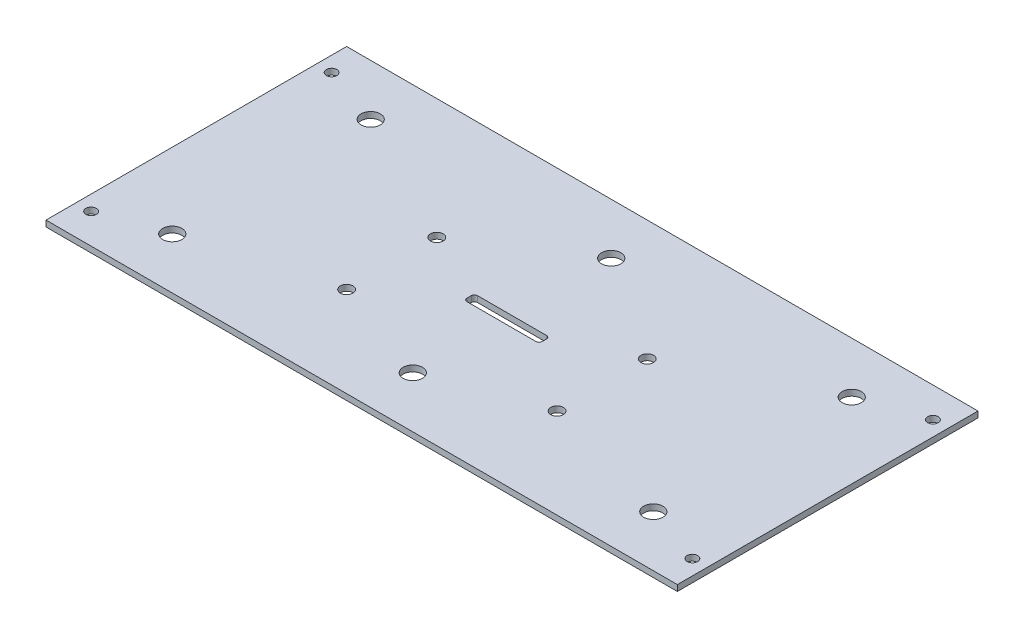
from build123d import *

# Parameters (mm, degrees)
SKETCH_1_W            = 210
SKETCH_1_H            = 100
SKETCH_1_R            = 3.2
SKETCH_1_R_2          = 1.75
EXTRUDE_1_DEPTH       = 2
HOLE_WIZARD_M41_D     = 4.2
HOLE_WIZARD_M41_DEPTH = 8
HOLE_WIZARD_M41_TIP   = 1.2618073
SKETCH_4_W            = 25
SKETCH_4_H            = 3.5
CUT_EXTRUDE_1_DEPTH   = 10
FILLET_1_R            = 1


with BuildPart() as part:
    # Эскиз1 → Бобышка-Вытянуть1 (new body)
    with BuildSketch(Plane(origin=(0, 0, 0), x_dir=(1, 0, 0), z_dir=(0, 1, 0))):
        with Locations((105, 50)):
            Rectangle(SKETCH_1_W, SKETCH_1_H)
        with Locations((105, 17)):
            Circle(SKETCH_1_R, mode=Mode.SUBTRACT)
        with Locations((185, 17)):
            Circle(SKETCH_1_R, mode=Mode.SUBTRACT)
        with Locations((25, 17)):
            Circle(SKETCH_1_R, mode=Mode.SUBTRACT)
        with Locations((25, 83)):
            Circle(SKETCH_1_R, mode=Mode.SUBTRACT)
        with Locations((105, 83)):
            Circle(SKETCH_1_R, mode=Mode.SUBTRACT)
        with Locations((185, 83)):
            Circle(SKETCH_1_R, mode=Mode.SUBTRACT)
        with Locations((5, 10)):
            Circle(SKETCH_1_R_2, mode=Mode.SUBTRACT)
        with Locations((5, 90)):
            Circle(SKETCH_1_R_2, mode=Mode.SUBTRACT)
        with Locations((205, 10)):
            Circle(SKETCH_1_R_2, mode=Mode.SUBTRACT)
        with Locations((205, 90)):
            Circle(SKETCH_1_R_2, mode=Mode.SUBTRACT)
    extrude(amount=EXTRUDE_1_DEPTH)

    # Сверло под метчик  спиральное M41
    with Locations(Plane(origin=(0, 2, 0), x_dir=(1, 0, 0), z_dir=(0, 1, 0))):
        with Locations((70, 60), (140, 60), (140, 30), (70, 30)):
            Hole(HOLE_WIZARD_M41_D / 2, depth=HOLE_WIZARD_M41_DEPTH)
            with Locations((0, 0, -(HOLE_WIZARD_M41_DEPTH + HOLE_WIZARD_M41_TIP / 2))):  # 118° drill point
                Cone(0, HOLE_WIZARD_M41_D / 2, HOLE_WIZARD_M41_TIP, mode=Mode.SUBTRACT)

    # Эскиз4 → Вырез-Вытянуть1 (cut)
    with BuildSketch(Plane(origin=(0, 2, 0), x_dir=(1, 0, 0), z_dir=(0, 1, 0))):
        with Locations((105, 48.25)):
            Rectangle(SKETCH_4_W, SKETCH_4_H)
    extrude(amount=-CUT_EXTRUDE_1_DEPTH, mode=Mode.SUBTRACT)

    # Скругление1
    fillet_1_edges = [part.edges().sort_by_distance(p)[0] for p in [
        (92.5, 1, -46.5),
        (92.5, 1, -50),
        (117.5, 1, -50),
        (117.5, 1, -46.5),
    ]]
    fillet(fillet_1_edges, radius=FILLET_1_R)


solid = part.part
